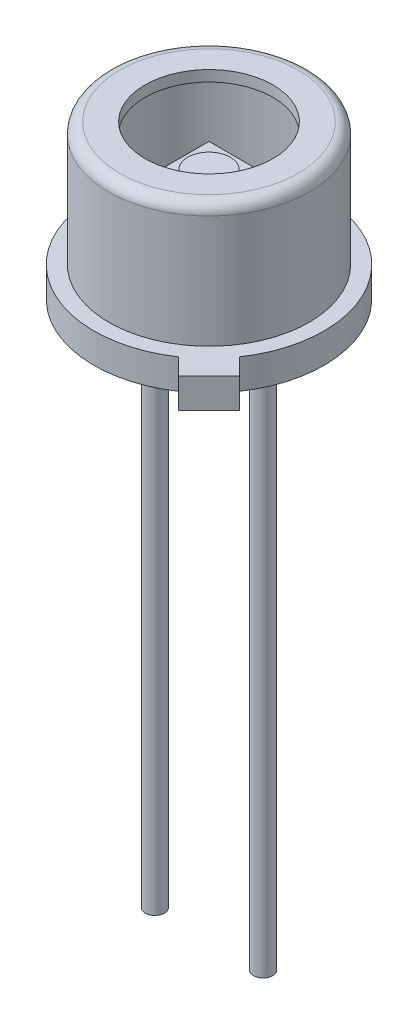
from build123d import *

# Parameters (mm, degrees)
SKETCH2_R           = 2.7
BOSS_EXTRUDE1_DEPTH = 0.446
BOSS_EXTRUDE2_START = -2.6
SKETCH3_W           = 1.2
SKETCH3_H           = 1.2
BOSS_EXTRUDE2_DEPTH = 0.05
SKETCH8_R           = 0.5
BOSS_EXTRUDE6_DEPTH = 0.03
BOSS_EXTRUDE7_DEPTH = 0.7
SKETCH5_R           = 0.225
BOSS_EXTRUDE8_DEPTH = 13


with BuildPart() as part:
    # Sketch1 → Revolve-Thin2 (revolve)
    with BuildSketch(Plane.XY, mode=Mode.PRIVATE) as revolve_thin2_sk:
        with BuildLine():
            Line((2.7, 0), (2.7, 0.7))
            Line((2.7, 0.7), (2.35, 0.7))
            Line((2.35, 0.7), (2.35, 3.346))
            ThreePointArc((2.35, 3.346), (2.275605122, 3.525605122), (2.096, 3.6))
            Line((2.096, 3.6), (1.5, 3.6))
            Line((1.5, 3.6), (1.5, 3.346))
            Line((1.5, 3.346), (2.096, 3.346))
            Line((2.096, 3.346), (2.096, 0.446))
            Line((2.096, 0.446), (2.446, 0.446))
            Line((2.446, 0.446), (2.446, 0))
            Line((2.446, 0), (2.7, 0))
        make_face()
    revolve(revolve_thin2_sk.sketch.rotate(Axis((0, 0, 0), (0, 1, 0)), 90), axis=Axis((0, 0, 0), (0, 1, 0)))  # turned: the seam where the file's is

    # Sketch2 → Boss-Extrude1 (add)
    with BuildSketch(Plane.XZ):
        with Locations(Location((0, 0, 0), (0, 0, 270))):  # turned: the seam where the file's is
            Circle(SKETCH2_R)
    extrude(amount=-BOSS_EXTRUDE1_DEPTH)

    # Sketch10 → Boss-Extrude7 (add)
    with BuildSketch(Plane.XZ):
        Polygon((1.520284949, 2.231307616), (2.231307616, 1.520284949), (2.618253033, 1.907230366), (1.907230366, 2.618253033), align=None)
    extrude(amount=-BOSS_EXTRUDE7_DEPTH)

    # Sketch5 → Boss-Extrude8 (add)
    with BuildSketch(Plane.XZ):
        with Locations(Location((-1.27, 0, 0), (0, 0, 90))):  # turned: the seam where the file's is
            Circle(SKETCH5_R)
        with Locations(Location((0, -1.27, 0), (0, 0, 90))):  # turned: the seam where the file's is
            Circle(SKETCH5_R)
        with Locations(Location((1.27, 0, 0), (0, 0, 270))):  # turned: the seam where the file's is
            Circle(SKETCH5_R)
    extrude(amount=BOSS_EXTRUDE8_DEPTH)


with BuildPart() as body_2:
    # Sketch3 → Boss-Extrude2 (new body)
    with BuildSketch(Plane.XZ.offset(BOSS_EXTRUDE2_START)):
        Rectangle(SKETCH3_W, SKETCH3_H)
    extrude(amount=BOSS_EXTRUDE2_DEPTH)

    # Sketch8 → Boss-Extrude6 (add)
    with BuildSketch(Plane(origin=(0, 2.6, 0), x_dir=(-1, 0, 0), z_dir=(0, 1, 0))):
        with Locations(Location((0, 0, 0), (0, 0, 270))):  # turned: the seam where the file's is
            Circle(SKETCH8_R)
    extrude(amount=BOSS_EXTRUDE6_DEPTH)


solid = Compound([part.part, body_2.part])
